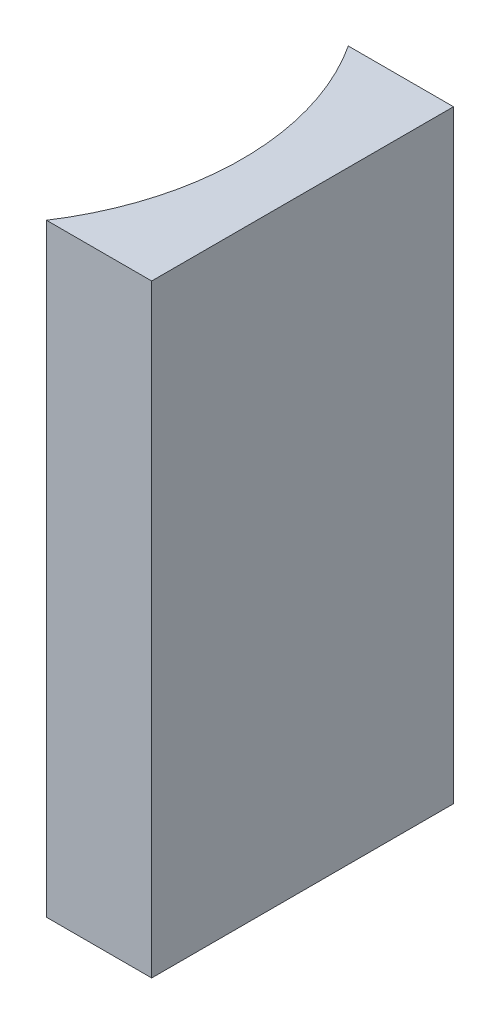
from build123d import *

# Parameters (mm, degrees)
EXTRUDE_1_DEPTH = 20


with BuildPart() as part:
    # 草图1 → 凸台-拉伸1 (new body)
    with BuildSketch(Plane(origin=(0, 0, 0), x_dir=(1, 0, 0), z_dir=(0, 1, 0))):
        with BuildLine():
            Line((0, 0), (0, -10))
            Line((0, -10), (-3.485001629, -10))
            ThreePointArc((-3.485001629, -10), (-2, -5), (-3.485001629, 0))
            Line((-3.485001629, 0), (0, 0))
        make_face()
    extrude(amount=EXTRUDE_1_DEPTH)


solid = part.part
